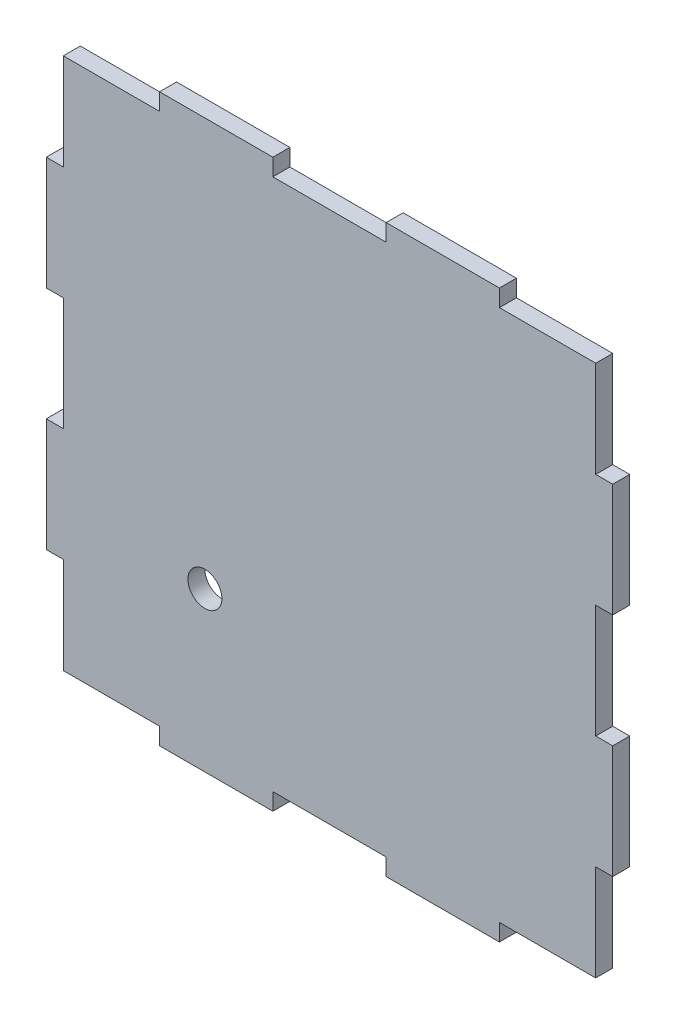
from build123d import *

# Parameters (mm, degrees)
SKETCH_1_R      = 3
EXTRUDE_2_DEPTH = 3


with BuildPart() as part:
    # 草图1 → 凸台-拉伸2 (new body)
    with BuildSketch(Plane.XY):
        Polygon((-10, 47), (10, 47), (10, 50), (30, 50), (30, 47), (47, 47), (47, 30), (50, 30), (50, 10), (47, 10), (47, -10), (50, -10), (50, -30), (47, -30), (47, -47), (30, -47), (30, -50), (10, -50), (10, -47), (-10, -47), (-10, -50), (-30, -50), (-30, -47), (-47, -47), (-47, -30), (-50, -30), (-50, -10), (-47, -10), (-47, 10), (-50, 10), (-50, 30), (-47, 30), (-47, 47), (-30, 47), (-30, 50), (-10, 50), align=None)
        with Locations((-22.001913568, -22.001913568)):
            Circle(SKETCH_1_R, mode=Mode.SUBTRACT)
    extrude(amount=EXTRUDE_2_DEPTH)


solid = part.part
